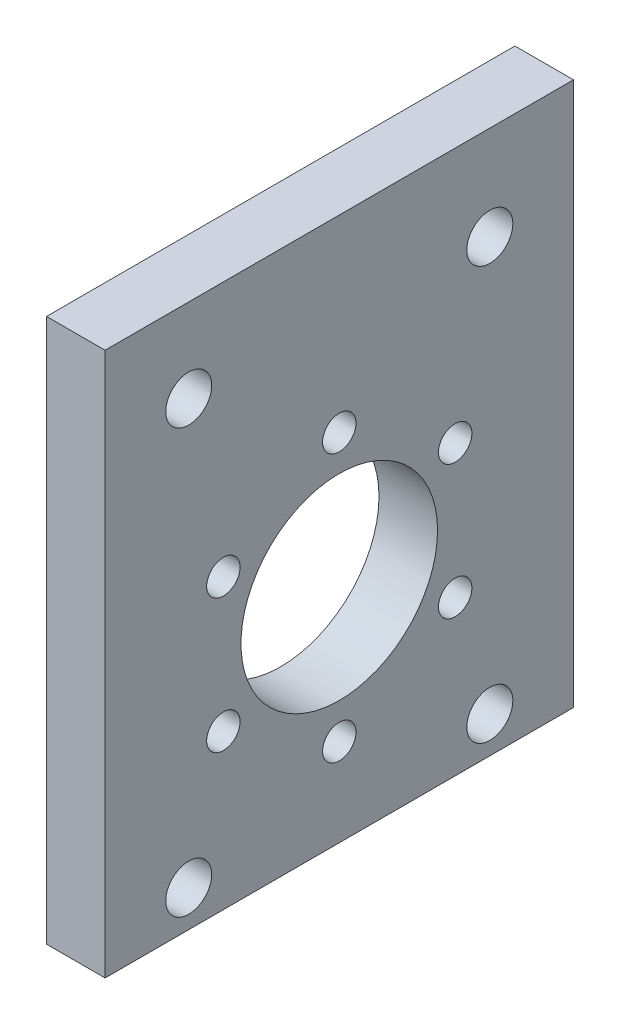
from build123d import *

# Parameters (mm, degrees)
SKETCH1_W           = 56
SKETCH1_H           = 65
BOSS_EXTRUDE1_DEPTH = 7
SKETCH2_R           = 11.75
CUT_EXTRUDE1_DEPTH  = 8
SKETCH3_R           = 2
CUT_EXTRUDE2_DEPTH  = 8
SKETCH4_R           = 2.75
CUT_EXTRUDE3_DEPTH  = 8


with BuildPart() as part:
    # Sketch1 → Boss-Extrude1 (new body)
    with BuildSketch(Plane(origin=(0, 0, 0), x_dir=(0, 0, -1), z_dir=(1, 0, 0))):
        with Locations((28, -32.5)):
            Rectangle(SKETCH1_W, SKETCH1_H)
    extrude(amount=BOSS_EXTRUDE1_DEPTH)

    # Sketch2 → Cut-Extrude1 (cut, through all)
    with BuildSketch(Plane(origin=(7, 0, 0), x_dir=(0, 0, -1), z_dir=(1, 0, 0))):
        with Locations((28, -38.52)):
            Circle(SKETCH2_R)
    extrude(amount=-CUT_EXTRUDE1_DEPTH, mode=Mode.SUBTRACT)

    # Sketch3 → Cut-Extrude2 (cut, through all)
    with BuildSketch(Plane.ZY):
        with Locations((-41.856406461, -30.52)):
            Circle(SKETCH3_R)
        with Locations((-28, -22.52)):
            Circle(SKETCH3_R)
        with Locations((-14.143593539, -30.52)):
            Circle(SKETCH3_R)
        with Locations((-14.143593539, -46.52)):
            Circle(SKETCH3_R)
        with Locations((-28, -54.52)):
            Circle(SKETCH3_R)
        with Locations((-41.856406461, -46.52)):
            Circle(SKETCH3_R)
    extrude(amount=-CUT_EXTRUDE2_DEPTH, mode=Mode.SUBTRACT)

    # Sketch4 → Cut-Extrude3 (cut, through all)
    with BuildSketch(Plane(origin=(7, 0, 0), x_dir=(0, 0, -1), z_dir=(1, 0, 0))):
        with Locations((10, -60.647707201)):
            Circle(SKETCH4_R)
        with Locations((10, -9.998526597)):
            Circle(SKETCH4_R)
        with Locations((46, -11.256698369)):
            Circle(SKETCH4_R)
        with Locations((46, -60.647707201)):
            Circle(SKETCH4_R)
    extrude(amount=-CUT_EXTRUDE3_DEPTH, mode=Mode.SUBTRACT)


solid = part.part
